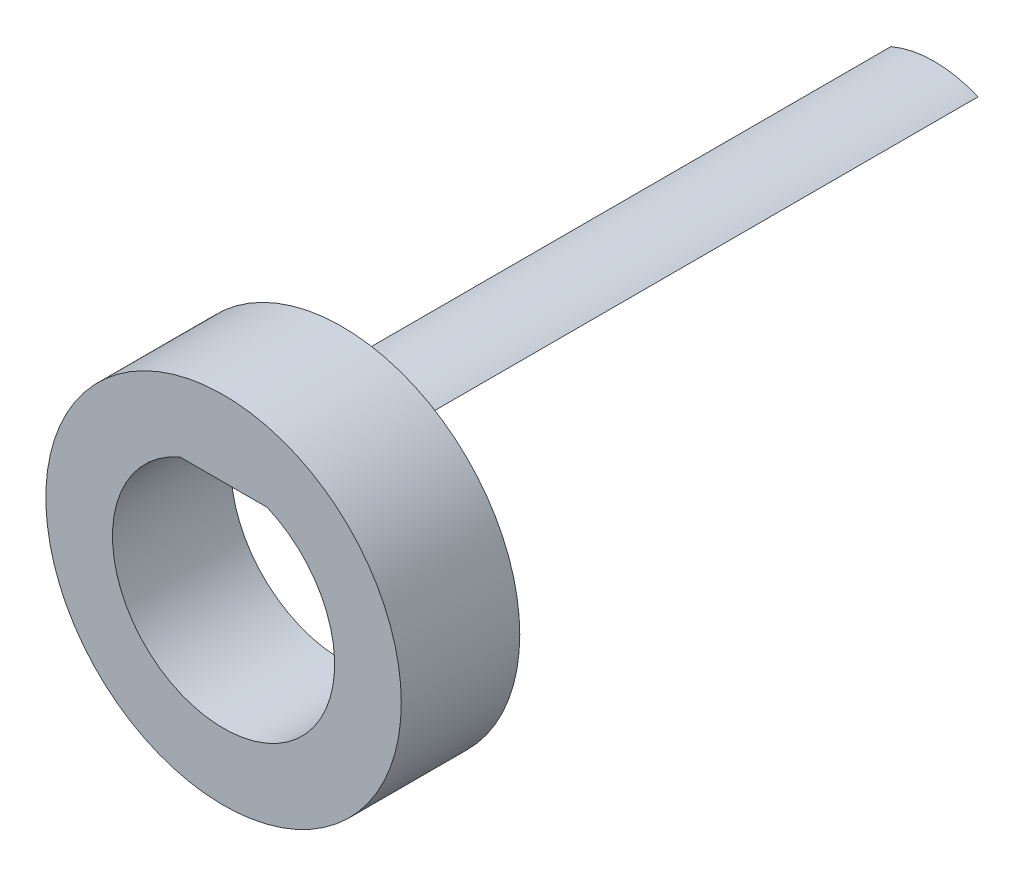
from build123d import *

# Parameters (mm, degrees)
SKETCH1_R           = 3.81
BOSS_EXTRUDE1_DEPTH = 2.54
BOSS_EXTRUDE2_DEPTH = 12.7


with BuildPart() as part:
    # Sketch1 → Boss-Extrude1 (new body)
    with BuildSketch(Plane.XY):
        Circle(SKETCH1_R)
        with BuildLine():
            Line((-0.933255592, 2.19075), (0.933255592, 2.19075))
            ThreePointArc((0.933255592, 2.19075), (0, -2.38125), (-0.933255592, 2.19075))
        make_face(mode=Mode.SUBTRACT)
    extrude(amount=BOSS_EXTRUDE1_DEPTH)

    # Sketch2 → Boss-Extrude2 (add)
    with BuildSketch(Plane(origin=(0, 0, 0), x_dir=(-1, 0, 0), z_dir=(0, 0, -1))):
        with BuildLine():
            Line((-0.933255592, 2.19075), (0.933255592, 2.19075))
            ThreePointArc((0.933255592, 2.19075), (0, 2.38125), (-0.933255592, 2.19075))
        make_face()
    extrude(amount=BOSS_EXTRUDE2_DEPTH)


solid = part.part
